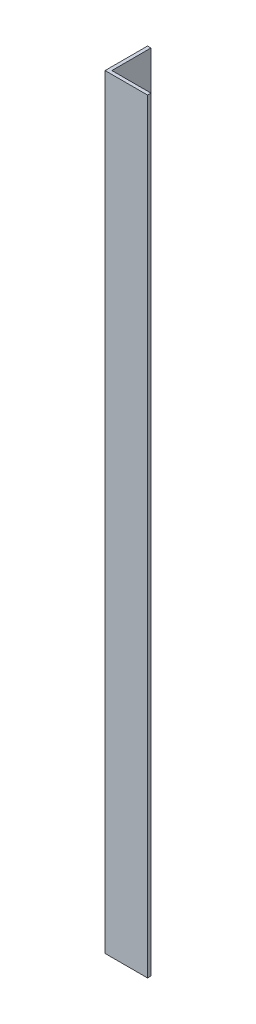
from build123d import *

# Parameters (mm, degrees)
EXTRUDE_1_DEPTH = 900


with BuildPart() as part:
    # Эскиз1 → Вытянуть-Тонкостенный1 (new body)
    with BuildSketch(Plane(origin=(0, 0, 0), x_dir=(1, 0, 0), z_dir=(0, 1, 0))):
        Polygon((0, 50), (0, 0), (50, 0), (50, 4), (4, 4), (4, 50), align=None)
    extrude(amount=EXTRUDE_1_DEPTH)


solid = part.part
